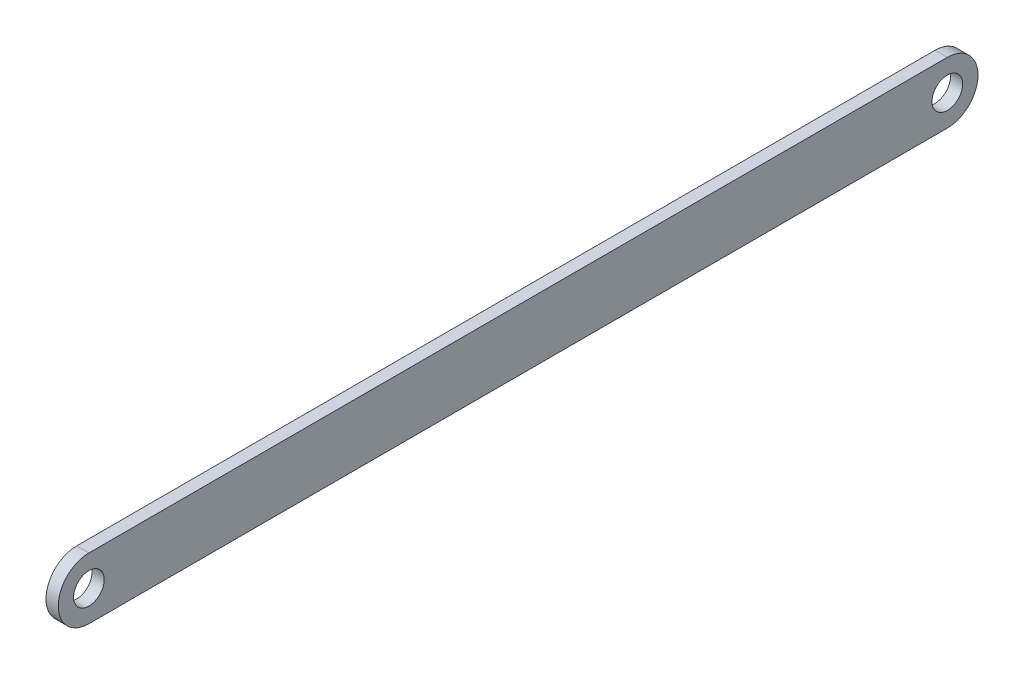
from build123d import *

# Parameters (mm, degrees)
SKETCH1_R           = 2.5
BOSS_EXTRUDE1_DEPTH = 1


with BuildPart() as part:
    # Sketch1 → Boss-Extrude1 (new body, symmetric)
    with BuildSketch(Plane(origin=(0, 0, 0), x_dir=(0, 0, -1), z_dir=(1, 0, 0))):
        with BuildLine():
            Line((-70, 5), (70, 5))
            ThreePointArc((70, 5), (75, 0), (70, -5))
            Line((70, -5), (-70, -5))
            ThreePointArc((-70, -5), (-75, 0), (-70, 5))
        make_face()
        with Locations((-70, 0)):
            Circle(SKETCH1_R, mode=Mode.SUBTRACT)
        with Locations((70, 0)):
            Circle(SKETCH1_R, mode=Mode.SUBTRACT)
    extrude(amount=BOSS_EXTRUDE1_DEPTH, both=True)


solid = part.part
